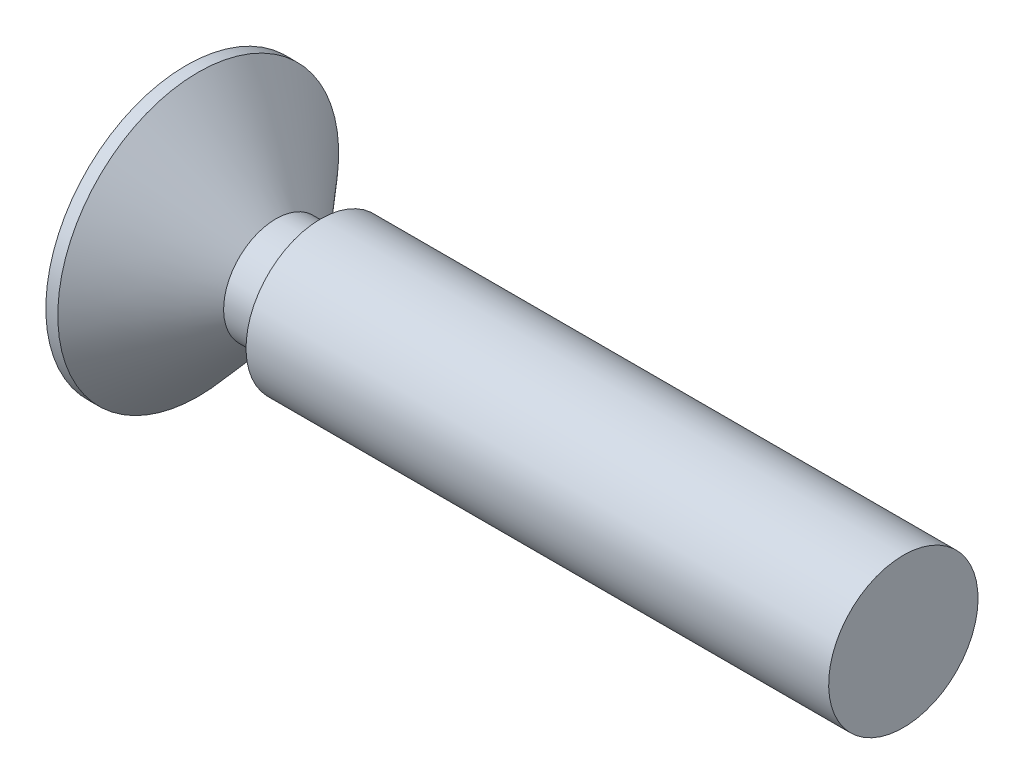
from build123d import *

# Parameters (mm, degrees)
CUT_EXTRUDE_1_DEPTH = 0.75


with BuildPart() as part:
    # 草图1 → 旋转1 (revolve)
    with BuildSketch(Plane.XY):
        Polygon((0, 0), (0, 1.25), (-9.75, 1.25), (-9.75, 0.875), (-10.5, 0.875), (-11.8, 2.35), (-12, 2.35), (-12, 0), align=None)
    revolve(axis=Axis((0, 0, 0), (-1, 0, 0)))

    # 草图2 → 切除-拉伸1 (cut)
    with BuildSketch(Plane.ZY.offset(12)):
        with BuildLine():
            Line((-0.3125, 1.5), (0.3125, 1.5))
            Line((0.3125, 1.5), (0.3125, 0.5625))
            ThreePointArc((0.3125, 0.5625), (0.385723305, 0.385723305), (0.5625, 0.3125))
            Line((0.5625, 0.3125), (1.5, 0.3125))
            Line((1.5, 0.3125), (1.5, -0.3125))
            Line((1.5, -0.3125), (0.5625, -0.3125))
            ThreePointArc((0.5625, -0.3125), (0.385723305, -0.385723305), (0.3125, -0.5625))
            Line((0.3125, -0.5625), (0.3125, -1.5))
            Line((0.3125, -1.5), (-0.3125, -1.5))
            Line((-0.3125, -1.5), (-0.3125, -0.5625))
            ThreePointArc((-0.3125, -0.5625), (-0.385723305, -0.385723305), (-0.5625, -0.3125))
            Line((-0.5625, -0.3125), (-1.5, -0.3125))
            Line((-1.5, -0.3125), (-1.5, 0.3125))
            Line((-1.5, 0.3125), (-0.5625, 0.3125))
            ThreePointArc((-0.5625, 0.3125), (-0.385723305, 0.385723305), (-0.3125, 0.5625))
            Line((-0.3125, 0.5625), (-0.3125, 1.5))
        make_face()
    extrude(amount=-CUT_EXTRUDE_1_DEPTH, mode=Mode.SUBTRACT)


solid = part.part
